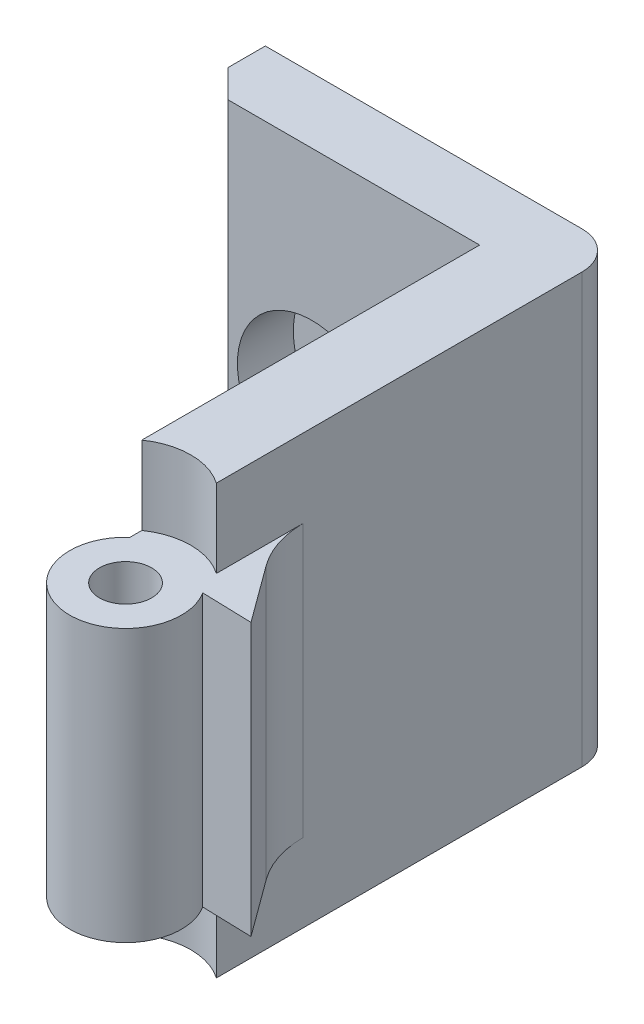
from build123d import *

# Parameters (mm, degrees)
SKETCH1_W           = 15
SKETCH1_H           = 3.5
BOSS_EXTRUDE1_DEPTH = 23
SKETCH3_R           = 3
BOSS_EXTRUDE2_DEPTH = 23
SKETCH4_R           = 1.4
CUT_EXTRUDE1_DEPTH  = 23
SKETCH5_R           = 3.5
CUT_EXTRUDE2_DEPTH  = 4.2
SKETCH6_R           = 3.5
CUT_EXTRUDE3_DEPTH  = 4.2
SKETCH7_R           = 4
CUT_EXTRUDE4_DEPTH  = 3
CHAMFER1_SIZE       = 1.5
BOSS_EXTRUDE3_DEPTH = 14.6
FILLET1_R           = 2
FILLET2_R           = 5


with BuildPart() as part:
    # Sketch1 → Boss-Extrude1 (new body)
    with BuildSketch(Plane(origin=(0, 0, 0), x_dir=(1, 0, 0), z_dir=(0, 1, 0))):
        with Locations((-12.213235294, 13.485294118)):
            Rectangle(SKETCH1_W, SKETCH1_H)
        Polygon((-0.713235294, 15.235294118), (-4.713235294, 15.235294118), (-4.713235294, 11.735294118), (-4.713235294, -9.264705882), (-0.713235294, -9.264705882), align=None)
    extrude(amount=BOSS_EXTRUDE1_DEPTH)

    # Sketch3 → Boss-Extrude2 (add)
    with BuildSketch(Plane.XZ):
        with Locations((-2.713235294, 9.264705882)):
            Circle(SKETCH3_R)
    extrude(amount=-BOSS_EXTRUDE2_DEPTH)

    # Sketch4 → Cut-Extrude1 (cut)
    with BuildSketch(Plane.XZ):
        with Locations((-2.713235294, 9.264705882)):
            Circle(SKETCH4_R)
    extrude(amount=-CUT_EXTRUDE1_DEPTH, mode=Mode.SUBTRACT)

    # Sketch5 → Cut-Extrude2 (cut)
    with BuildSketch(Plane.XZ):
        with Locations((-2.713235294, 9.264705882)):
            Circle(SKETCH5_R)
    extrude(amount=-CUT_EXTRUDE2_DEPTH, mode=Mode.SUBTRACT)

    # Sketch6 → Cut-Extrude3 (cut)
    with BuildSketch(Plane(origin=(0, 23, 0), x_dir=(1, 0, 0), z_dir=(0, 1, 0))):
        with Locations((-2.713235294, -9.264705882)):
            Circle(SKETCH6_R)
    extrude(amount=-CUT_EXTRUDE3_DEPTH, mode=Mode.SUBTRACT)

    # Sketch7 → Cut-Extrude4 (cut)
    with BuildSketch(Plane.XY.offset(-11.735294118)):
        with Locations((-13.713235294, 11)):
            Circle(SKETCH7_R)
    extrude(amount=-CUT_EXTRUDE4_DEPTH, mode=Mode.SUBTRACT)

    # Chamfer1
    chamfer1_edges = [part.edges().sort_by_distance(p)[0] for p in [
        (-19.713235294, 11.5, -11.735294118),
    ]]
    chamfer(chamfer1_edges, length=CHAMFER1_SIZE)

    # Sketch8 → Boss-Extrude3 (add)
    with BuildSketch(Plane(origin=(0, 18.8, 0), x_dir=(1, 0, 0), z_dir=(0, 1, 0))):
        Polygon((-0.92234324, -7.637497627), (2.489493511, -7.736371955), (-0.92234324, -3.081041661), align=None)
    extrude(amount=-BOSS_EXTRUDE3_DEPTH)

    # Fillet1
    fillet1_edges = [part.edges().sort_by_distance(p)[0] for p in [
        (-0.713235294, 11.5, -15.235294118),
    ]]
    fillet(fillet1_edges, radius=FILLET1_R)

    # Fillet2
    fillet2_edges = [part.edges().sort_by_distance(p)[0] for p in [
        (-0.713235294, 11.5, 3.36636204),
    ]]
    fillet(fillet2_edges, radius=FILLET2_R)


solid = part.part
